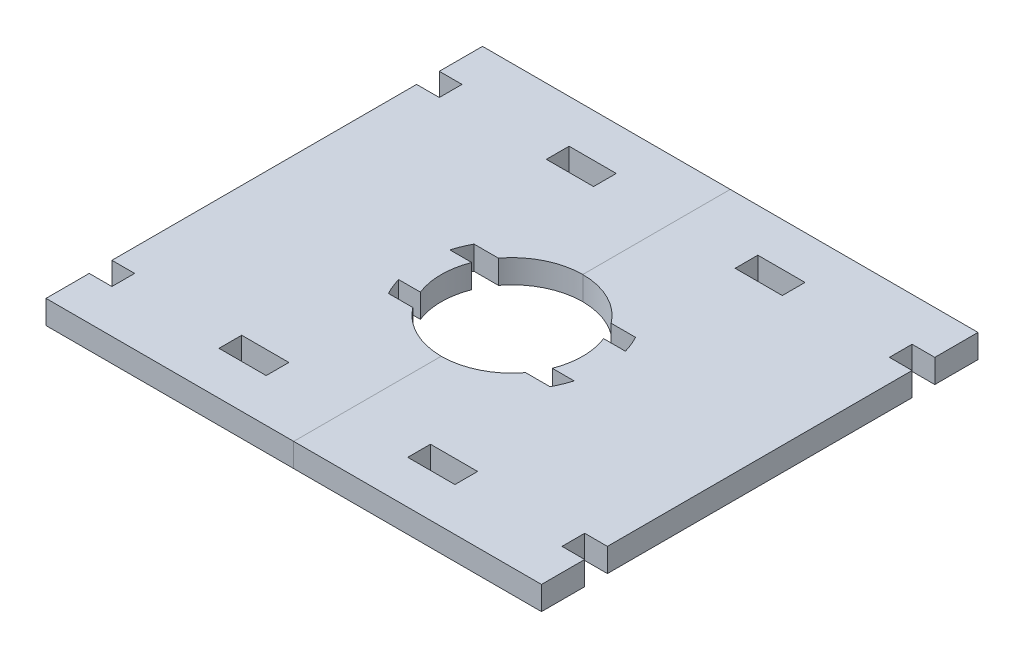
from build123d import *

# Parameters (mm, degrees)
SKETCH2_W               = 84
SKETCH2_H               = 74
BOSS_EXTRUDE1_DEPTH     = 4
SKETCH4_W               = 8
SKETCH4_H               = 3.85
SKETCH4_W_2             = 3.85
CUT_EXTRUDE2_DEPTH      = 1
CUT_EXTRUDE2_DEPTH_BACK = 5


with BuildPart() as part:
    # Sketch2 → Boss-Extrude1 (new body)
    with BuildSketch(Plane(origin=(0, 0, 0), x_dir=(1, 0, 0), z_dir=(0, 1, 0))):
        Rectangle(SKETCH2_W, SKETCH2_H)
        with BuildLine():
            ThreePointArc((11.183805256, 4.35), (12, 0), (11.183805256, -4.35))
            Line((11.183805256, -4.35), (14.877079687, -4.35))
            ThreePointArc((14.877079687, -4.35), (14.361878956, -5.829788405), (13.699908759, -7.25))
            Line((13.699908759, -7.25), (9.562295749, -7.25))
            ThreePointArc((9.562295749, -7.25), (0, -12), (-9.562295749, -7.25))
            Line((-9.562295749, -7.25), (-13.699908759, -7.25))
            ThreePointArc((-13.699908759, -7.25), (-14.361878956, -5.829788405), (-14.877079687, -4.35))
            Line((-14.877079687, -4.35), (-11.183805256, -4.35))
            ThreePointArc((-11.183805256, -4.35), (-12, 0), (-11.183805256, 4.35))
            Line((-11.183805256, 4.35), (-14.877079687, 4.35))
            ThreePointArc((-14.877079687, 4.35), (-14.361878956, 5.829788405), (-13.699908759, 7.25))
            Line((-13.699908759, 7.25), (-9.562295749, 7.25))
            ThreePointArc((-9.562295749, 7.25), (0, 12), (9.562295749, 7.25))
            Line((9.562295749, 7.25), (13.699908759, 7.25))
            ThreePointArc((13.699908759, 7.25), (14.361878956, 5.829788405), (14.877079687, 4.35))
            Line((14.877079687, 4.35), (11.183805256, 4.35))
        make_face(mode=Mode.SUBTRACT)
    extrude(amount=BOSS_EXTRUDE1_DEPTH)


with BuildPart() as body_2:
    # Split1: the piece on the far side of the plane
    add(part.part)
    split(bisect_by=Plane(origin=(0, 0, 0), x_dir=(0, 0, 1), z_dir=(1, 0, 0)), keep=Keep.BOTTOM)


with BuildPart() as part_1:
    add(part.part)

    # Split1
    split(bisect_by=Plane(origin=(0, 0, 0), x_dir=(0, 0, 1), z_dir=(1, 0, 0)), keep=Keep.TOP)


with BuildPart() as cut_extrude2_tool:
    # Sketch4 → Cut-Extrude2 (new body, two sides)
    with BuildSketch(Plane(origin=(0, 4, 0), x_dir=(1, 0, 0), z_dir=(0, 1, 0))) as cut_extrude2_sk:
        with Locations((-16, -27.75)):
            Rectangle(SKETCH4_W, SKETCH4_H)
        with Locations((-40.075, -27.75)):
            Rectangle(SKETCH4_W_2, SKETCH4_H)
        with Locations((40.075, -27.75)):
            Rectangle(SKETCH4_W_2, SKETCH4_H)
        with Locations((16, -27.75)):
            Rectangle(SKETCH4_W, SKETCH4_H)
        with Locations((16, 27.75)):
            Rectangle(SKETCH4_W, SKETCH4_H)
        with Locations((40.075, 27.75)):
            Rectangle(SKETCH4_W_2, SKETCH4_H)
        with Locations((-40.075, 27.75)):
            Rectangle(SKETCH4_W_2, SKETCH4_H)
        with Locations((-16, 27.75)):
            Rectangle(SKETCH4_W, SKETCH4_H)
    extrude(amount=CUT_EXTRUDE2_DEPTH)
    extrude(cut_extrude2_sk.sketch, amount=-CUT_EXTRUDE2_DEPTH_BACK)


with BuildPart() as part_2:
    add(part_1.part)

    # Cut-Extrude2: cut by cut_extrude2_tool
    add(cut_extrude2_tool.part, mode=Mode.SUBTRACT)


with BuildPart() as body_2_1:
    add(body_2.part)

    # Cut-Extrude2: cut by cut_extrude2_tool
    add(cut_extrude2_tool.part, mode=Mode.SUBTRACT)


solid = Compound([part_2.part, body_2_1.part])
